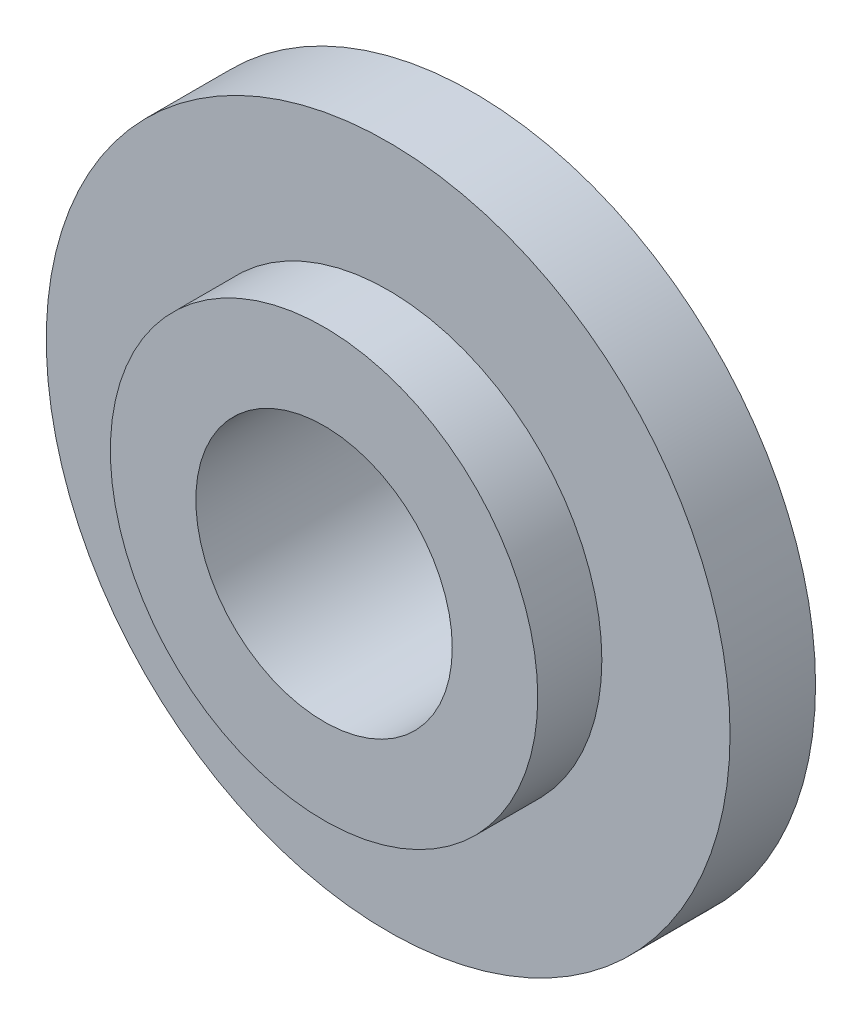
from build123d import *

# Parameters (mm, degrees)
SKETCH_1_R      = 50
SKETCH_1_R_2    = 30
EXTRUDE_1_DEPTH = 25
SKETCH_2_R      = 80
SKETCH_2_R_2    = 50
EXTRUDE_2_DEPTH = 10


with BuildPart() as part:
    # 草图1 → 凸台-拉伸1 (new body, symmetric)
    with BuildSketch(Plane.XY):
        Circle(SKETCH_1_R)
        Circle(SKETCH_1_R_2, mode=Mode.SUBTRACT)
    extrude(amount=EXTRUDE_1_DEPTH, both=True)

    # 草图2 → 凸台-拉伸2 (add, symmetric)
    with BuildSketch(Plane.XY):
        Circle(SKETCH_2_R)
        Circle(SKETCH_2_R_2, mode=Mode.SUBTRACT)
    extrude(amount=EXTRUDE_2_DEPTH, both=True)


solid = part.part
